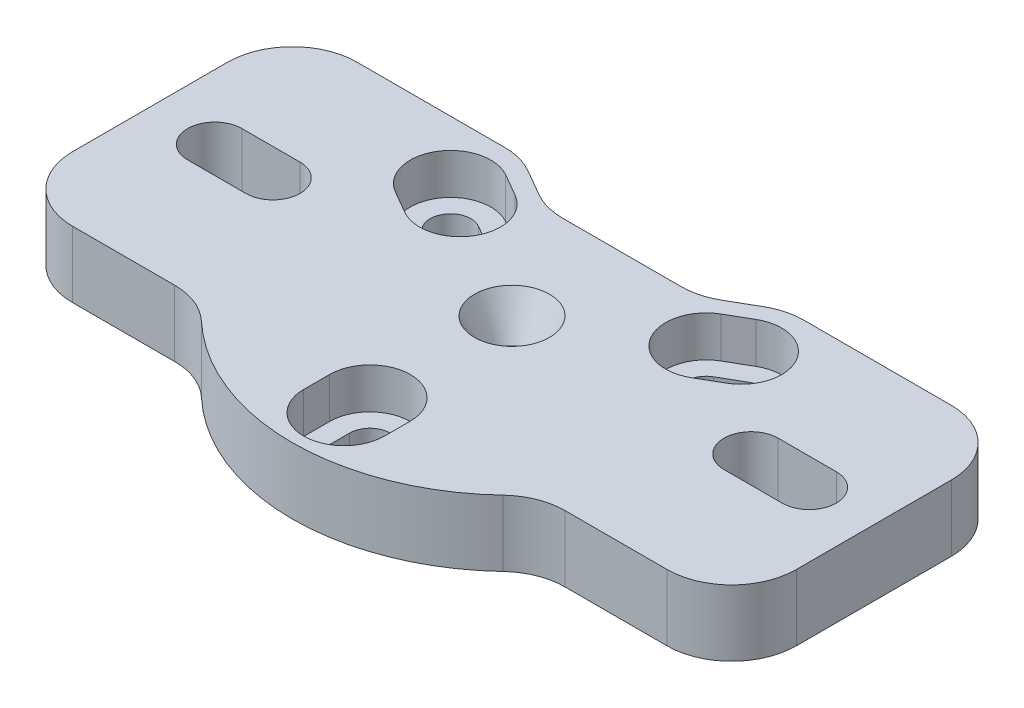
from build123d import *

# Parameters (mm, degrees)
SKETCH1_R           = 1.778
BOSS_EXTRUDE1_DEPTH = 6.5
CUT_EXTRUDE1_DEPTH  = 4
CHAMFER1_SIZE       = 1.905
CHAMFER1_SIZE2      = 3.81


with BuildPart() as part:
    # Sketch1 → Boss-Extrude1 (new body)
    with BuildSketch(Plane(origin=(0, 0, 0), x_dir=(1, 0, 0), z_dir=(0, 1, 0))):
        with BuildLine():
            Line((14.722227154, 13.97), (29.21, 13.97))
            ThreePointArc((29.21, 13.97), (33.700128061, 12.110128061), (35.56, 7.62))
            Line((35.56, 7.62), (35.56, -7.62))
            ThreePointArc((35.56, -7.62), (33.700128061, -12.110128061), (29.21, -13.97))
            Line((29.21, -13.97), (19.176579466, -13.97))
            ThreePointArc((19.176579466, -13.97), (16.831686562, -14.418815604), (14.818265951, -15.701818182))
            ThreePointArc((14.818265951, -15.701818182), (0, -21.59), (-14.818265951, -15.701818182))
            ThreePointArc((-14.818265951, -15.701818182), (-16.831686562, -14.418815604), (-19.176579466, -13.97))
            Line((-19.176579466, -13.97), (-29.21, -13.97))
            ThreePointArc((-29.21, -13.97), (-33.700128061, -12.110128061), (-35.56, -7.62))
            Line((-35.56, -7.62), (-35.56, 7.62))
            ThreePointArc((-35.56, 7.62), (-33.700128061, 12.110128061), (-29.21, 13.97))
            Line((-29.21, 13.97), (-14.722227154, 13.97))
            ThreePointArc((-14.722227154, 13.97), (-13.078726217, 13.753628997), (-11.547227154, 13.119261314))
            Line((-11.547227154, 13.119261314), (-8.995011096, 11.645738686))
            ThreePointArc((-8.995011096, 11.645738686), (-7.463512032, 11.011371003), (-5.820011096, 10.795))
            Line((-5.820011096, 10.795), (5.820011096, 10.795))
            ThreePointArc((5.820011096, 10.795), (7.463512032, 11.011371003), (8.995011096, 11.645738686))
            Line((8.995011096, 11.645738686), (11.547227154, 13.119261314))
            ThreePointArc((11.547227154, 13.119261314), (13.078726217, 13.753628997), (14.722227154, 13.97))
        make_face()
        with Locations(Location((0, 0, 0), (0, 0, 270))):  # turned: the seam where the file's is
            Circle(SKETCH1_R, mode=Mode.SUBTRACT)
        with BuildLine():
            Line((-23.495, -2.667), (-29.21, -2.667))
            ThreePointArc((-29.21, -2.667), (-31.877, 0), (-29.21, 2.667))
            Line((-29.21, 2.667), (-23.495, 2.667))
            ThreePointArc((-23.495, 2.667), (-20.828, 0), (-23.495, -2.667))
        make_face(mode=Mode.SUBTRACT)
        with BuildLine():
            Line((23.495, 2.667), (29.21, 2.667))
            ThreePointArc((29.21, 2.667), (31.877, 0), (29.21, -2.667))
            Line((29.21, -2.667), (23.495, -2.667))
            ThreePointArc((23.495, -2.667), (20.828, 0), (23.495, 2.667))
        make_face(mode=Mode.SUBTRACT)
        with BuildLine():
            Line((-15.289419162, 6.517949192), (-13.089714637, 5.247949192))
            ThreePointArc((-13.089714637, 5.247949192), (-10.357663829, 5.98), (-11.089714637, 8.712050808))
            Line((-11.089714637, 8.712050808), (-13.289419162, 9.982050808))
            ThreePointArc((-13.289419162, 9.982050808), (-16.02146997, 9.25), (-15.289419162, 6.517949192))
        make_face(mode=Mode.SUBTRACT)
        with BuildLine():
            Line((13.289419162, 9.982050808), (11.089714637, 8.712050808))
            ThreePointArc((11.089714637, 8.712050808), (10.357663829, 5.98), (13.089714637, 5.247949192))
            Line((13.089714637, 5.247949192), (15.289419162, 6.517949192))
            ThreePointArc((15.289419162, 6.517949192), (16.02146997, 9.25), (13.289419162, 9.982050808))
        make_face(mode=Mode.SUBTRACT)
        with BuildLine():
            Line((2, -16.5), (2, -13.96))
            ThreePointArc((2, -13.96), (0, -11.96), (-2, -13.96))
            Line((-2, -13.96), (-2, -16.5))
            ThreePointArc((-2, -16.5), (0, -18.5), (2, -16.5))
        make_face(mode=Mode.SUBTRACT)
    extrude(amount=BOSS_EXTRUDE1_DEPTH)

    # Sketch5 → Cut-Extrude1 (cut)
    with BuildSketch(Plane(origin=(0, 6.5, 0), x_dir=(1, 0, 0), z_dir=(0, 1, 0))):
        with BuildLine():
            Line((-3.96875, -13.96), (-3.96875, -16.5))
            ThreePointArc((-3.96875, -16.5), (0, -20.46875), (3.96875, -16.5))
            Line((3.96875, -16.5), (3.96875, -13.96))
            ThreePointArc((3.96875, -13.96), (0, -9.99125), (-3.96875, -13.96))
        make_face()
        with BuildLine():
            Line((12.305044162, 11.687038321), (10.105339637, 10.417038321))
            ThreePointArc((10.105339637, 10.417038321), (8.652676316, 4.995625), (14.074089637, 3.542961679))
            Line((14.074089637, 3.542961679), (16.273794162, 4.812961679))
            ThreePointArc((16.273794162, 4.812961679), (17.726457484, 10.234375), (12.305044162, 11.687038321))
        make_face()
        with BuildLine():
            Line((-12.305044162, 11.687038321), (-10.105339637, 10.417038321))
            ThreePointArc((-10.105339637, 10.417038321), (-8.652676316, 4.995625), (-14.074089637, 3.542961679))
            Line((-14.074089637, 3.542961679), (-16.273794162, 4.812961679))
            ThreePointArc((-16.273794162, 4.812961679), (-17.726457484, 10.234375), (-12.305044162, 11.687038321))
        make_face()
    extrude(amount=-CUT_EXTRUDE1_DEPTH, mode=Mode.SUBTRACT)

    # Chamfer1
    chamfer1_edges = [part.edges().sort_by_distance(p)[0] for p in [
        (0, 6.5, -1.778),
    ]]
    chamfer1_side = [part.faces().sort_by_distance(p)[0] for p in [
        (0, 6.5, 2.195443335),
    ]]
    chamfer(chamfer1_edges, length=CHAMFER1_SIZE, length2=CHAMFER1_SIZE2, reference=chamfer1_side[0])


solid = part.part
